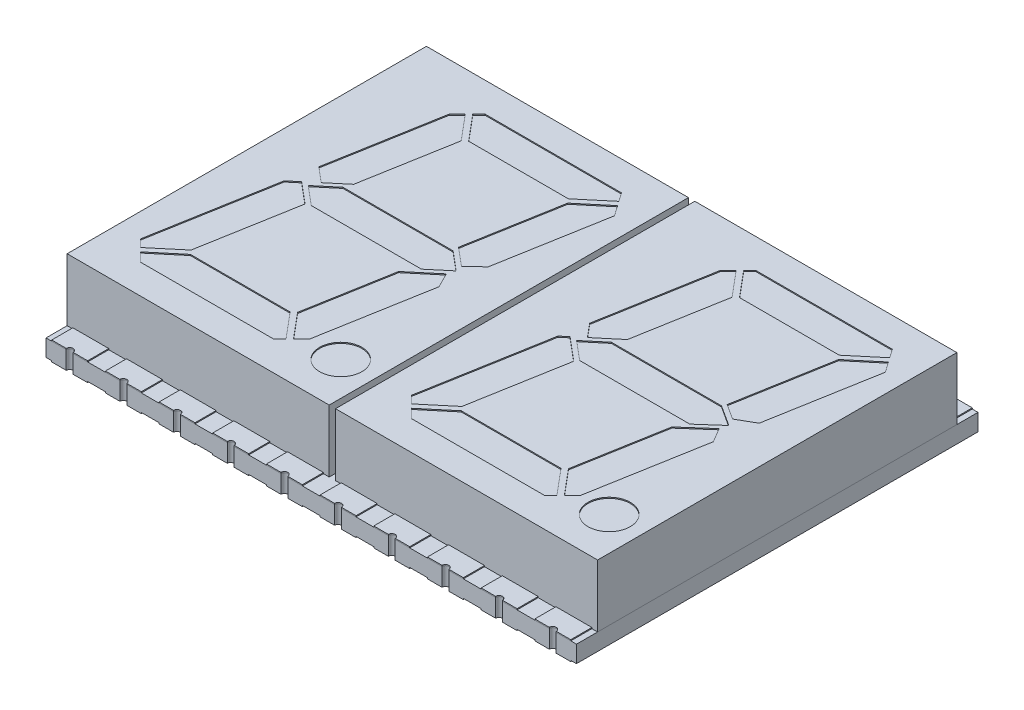
from build123d import *

# Parameters (mm, degrees)
SKETCH1_W          = 25.1
SKETCH1_H          = 17
EXTRUDE1_DEPTH     = 2.95
SKETCH2_R          = 1
CUT_EXTRUDE1_DEPTH = 0.05
SKETCH3_W          = 25.1
SKETCH3_H          = 19
EXTRUDE2_DEPTH     = 0.8
EXTRUDE3_DEPTH     = 0.05
EXTRUDE3_2_DEPTH   = 0.05
EXTRUDE3_3_DEPTH   = 0.05
EXTRUDE3_4_DEPTH   = 0.05
EXTRUDE3_5_DEPTH   = 0.05
EXTRUDE3_6_DEPTH   = 0.05
EXTRUDE3_7_DEPTH   = 0.05
EXTRUDE3_8_DEPTH   = 0.05
EXTRUDE3_9_DEPTH   = 0.05
EXTRUDE3_10_DEPTH  = 0.05
EXTRUDE3_11_DEPTH  = 0.05
EXTRUDE3_12_DEPTH  = 0.05
EXTRUDE3_13_DEPTH  = 0.05
EXTRUDE3_14_DEPTH  = 0.05
EXTRUDE3_15_DEPTH  = 0.05
EXTRUDE3_16_DEPTH  = 0.05
EXTRUDE3_17_DEPTH  = 0.05
EXTRUDE3_18_DEPTH  = 0.05
EXTRUDE3_19_DEPTH  = 0.05
EXTRUDE3_20_DEPTH  = 0.05
SKETCH5_W          = 1.7
SKETCH5_H          = 1.5
EXTRUDE4_DEPTH     = 0.05
SKETCH10_5_R       = 0.1625
CUT_EXTRUDE2_DEPTH = 1.85
CUT_EXTRUDE5_START = -3.8
SKETCH13_W         = 0.3
SKETCH13_H         = 17
CUT_EXTRUDE5_DEPTH = 3.8


with BuildPart() as part:
    # Sketch1 → Extrude1 (new body)
    with BuildSketch(Plane(origin=(0, 0, 0), x_dir=(1, 0, 0), z_dir=(0, 1, 0))):
        Rectangle(SKETCH1_W, SKETCH1_H)
    extrude(amount=-EXTRUDE1_DEPTH)

    # Sketch2 → Cut-Extrude1 (cut)
    with BuildSketch(Plane(origin=(0, 0, 0), x_dir=(-1, 0, 0), z_dir=(0, 1, 0))):
        Polygon((8.852866064, -6.641245818), (9.232640019, -6.261471863), (10.157474308, -1.016475976), (9.44999247, -0.422828228), (8.615549782, -1.12300878), (7.852707368, -5.449303098), align=None)
        Polygon((1.928929028, -7.11), (8.384111882, -7.11), (8.675414111, -6.818697771), (7.661196257, -5.61), (2.941704587, -5.61), (1.642158235, -6.700448864), align=None)
        Polygon((9.95389953, 0), (10.403180171, 0.37699122), (11.422070575, 6.155405845), (11.068538667, 6.508937754), (9.768992316, 5.418488889), (8.960539945, 0.833527661), align=None)
        Polygon((1.154600839, -6.00414474), (1.498216384, -6.494878596), (2.781007684, -5.418488889), (3.55537083, -1.026857262), (2.693597993, -0.303743992), (2.049432878, -0.929300064), align=None)
        Polygon((8.74893957, -0.75), (9.642754764, 0), (8.74893957, 0.75), (3.536569959, 0.75), (2.642754764, 0), (3.536569959, -0.75), align=None)
        Polygon((9.608295413, 5.61), (10.891086714, 6.686389707), (10.467476421, 7.11), (4.165888118, 7.11), (3.874585889, 6.818697771), (4.888803743, 5.61), align=None)
        Polygon((2.753218376, 0.353771434), (3.980378506, 1.383481046), (4.697292632, 5.449303098), (3.697133936, 6.641245818), (3.317359981, 6.261471863), (2.399465611, 1.055834211), align=None)
        Polygon((-1.926170809, 6.686369054), (-2.349801757, 7.110000002), (-8.65139006, 7.110000002), (-8.942693927, 6.818696135), (-7.928477445, 5.61), (-3.208937491, 5.61), align=None)
        Polygon((-1.395207603, 6.155405848), (-1.748760165, 6.50895841), (-3.048277997, 5.418533472), (-3.841622667, 0.919252271), (-2.746100468, -1e-09), (-2.43446315, 0.261494758), align=None)
        Polygon((-8.119985018, 5.449306065), (-9.120142603, 6.641247459), (-9.499918197, 6.261471865), (-10.442385385, 0.91647484), (-10.042176652, 0.239816778), (-8.853130118, 1.291433592), align=None)
        Polygon((-3.95106043, 0.75), (-9.163430041, 0.75), (-10.143402684, -0.116707634), (-9.163430041, -0.75), (-3.95106043, -0.75), (-3.057245236, 0), align=None)
        Polygon((-2.65980387, -1.016475974), (-3.193889851, -0.375739907), (-4.222093533, -1.238505238), (-4.964570806, -5.449303098), (-3.964412113, -6.641245814), (-3.584638159, -6.26147186), align=None)
        Polygon((-9.245703338, -0.934959776), (-9.96734652, -0.468608882), (-10.7678453, -0.929300061), (-11.662677339, -6.004144738), (-11.319061794, -6.494878594), (-10.036270496, -5.418488889), align=None)
        Polygon((-4.141864066, -6.818697768), (-5.156081917, -5.61), (-9.875573594, -5.61), (-11.175119943, -6.700448862), (-10.88834915, -7.109999998), (-4.433166296, -7.109999998), align=None)
        with Locations(Location((1.742754764, 6.36, 0), (0, 0, 90))):  # turned: the seam where the file's is
            Circle(SKETCH2_R)
        with Locations(Location((-10.957245236, 6.36, 0), (0, 0, 90))):  # turned: the seam where the file's is
            Circle(SKETCH2_R)
    extrude(amount=-CUT_EXTRUDE1_DEPTH, mode=Mode.SUBTRACT)

    # Sketch13 → Cut-Extrude5 (cut)
    with BuildSketch(Plane(origin=(0, 0, 0), x_dir=(-1, 0, 0), z_dir=(0, 1, 0)).offset(CUT_EXTRUDE5_START)):
        Rectangle(SKETCH13_W, SKETCH13_H)
    extrude(amount=CUT_EXTRUDE5_DEPTH, mode=Mode.SUBTRACT)


with BuildPart() as body_2:
    # Sketch3 → Extrude2 (new body)
    with BuildSketch(Plane.XZ.offset(2.95)):
        Rectangle(SKETCH3_W, SKETCH3_H)
    extrude(amount=EXTRUDE2_DEPTH)

    # Sketch5 → Extrude4 (add)
    with BuildSketch(Plane.XZ.offset(3.75)):
        with Locations((11.43, -8.75)):
            Rectangle(SKETCH5_W, SKETCH5_H)
        with Locations((8.89, -8.75)):
            Rectangle(SKETCH5_W, SKETCH5_H)
        with Locations((6.35, -8.75)):
            Rectangle(SKETCH5_W, SKETCH5_H)
        with Locations((3.81, -8.75)):
            Rectangle(SKETCH5_W, SKETCH5_H)
        with Locations((1.27, -8.75)):
            Rectangle(SKETCH5_W, SKETCH5_H)
        with Locations((-1.27, -8.75)):
            Rectangle(SKETCH5_W, SKETCH5_H)
        with Locations((-3.81, -8.75)):
            Rectangle(SKETCH5_W, SKETCH5_H)
        with Locations((-6.35, -8.75)):
            Rectangle(SKETCH5_W, SKETCH5_H)
        with Locations((-8.89, -8.75)):
            Rectangle(SKETCH5_W, SKETCH5_H)
        with Locations((-11.43, -8.75)):
            Rectangle(SKETCH5_W, SKETCH5_H)
        with Locations((11.43, 8.75)):
            Rectangle(SKETCH5_W, SKETCH5_H)
        with Locations((8.89, 8.75)):
            Rectangle(SKETCH5_W, SKETCH5_H)
        with Locations((6.35, 8.75)):
            Rectangle(SKETCH5_W, SKETCH5_H)
        with Locations((3.81, 8.75)):
            Rectangle(SKETCH5_W, SKETCH5_H)
        with Locations((1.27, 8.75)):
            Rectangle(SKETCH5_W, SKETCH5_H)
        with Locations((-1.27, 8.75)):
            Rectangle(SKETCH5_W, SKETCH5_H)
        with Locations((-3.81, 8.75)):
            Rectangle(SKETCH5_W, SKETCH5_H)
        with Locations((-6.35, 8.75)):
            Rectangle(SKETCH5_W, SKETCH5_H)
        with Locations((-8.89, 8.75)):
            Rectangle(SKETCH5_W, SKETCH5_H)
        with Locations((-11.43, 8.75)):
            Rectangle(SKETCH5_W, SKETCH5_H)
    extrude(amount=EXTRUDE4_DEPTH)

    # Sketch10_5 → Cut-Extrude2 (cut, through all)
    with BuildSketch(Plane(origin=(0, -2.95, 0), x_dir=(-1, 0, 0), z_dir=(0, 1, 0))):
        with BuildLine():
            ThreePointArc((11.2675, 9.5), (11.43, 9.3375), (11.5925, 9.5))
            Line((11.5925, 9.5), (11.2675, 9.5))
        make_face()
        with BuildLine():
            Line((11.2675, 9.5), (11.5925, 9.5))
            ThreePointArc((11.5925, 9.5), (11.43, 9.6625), (11.2675, 9.5))
        make_face()
        with Locations((-6.35, -9.5)):
            Circle(SKETCH10_5_R)
        with Locations((-11.43, -9.5)):
            Circle(SKETCH10_5_R)
        with Locations((-8.89, -9.5)):
            Circle(SKETCH10_5_R)
        with Locations((-3.81, -9.5)):
            Circle(SKETCH10_5_R)
        with Locations((-1.27, -9.5)):
            Circle(SKETCH10_5_R)
        with Locations((1.27, -9.5)):
            Circle(SKETCH10_5_R)
        with Locations((3.81, -9.5)):
            Circle(SKETCH10_5_R)
        with Locations((6.35, -9.5)):
            Circle(SKETCH10_5_R)
        with Locations((8.89, -9.5)):
            Circle(SKETCH10_5_R)
        with Locations((11.43, -9.5)):
            Circle(SKETCH10_5_R)
        with Locations((-11.43, 9.5)):
            Circle(SKETCH10_5_R)
        with Locations((-8.89, 9.5)):
            Circle(SKETCH10_5_R)
        with Locations((-6.35, 9.5)):
            Circle(SKETCH10_5_R)
        with Locations((-3.81, 9.5)):
            Circle(SKETCH10_5_R)
        with Locations((-1.27, 9.5)):
            Circle(SKETCH10_5_R)
        with Locations((1.27, 9.5)):
            Circle(SKETCH10_5_R)
        with Locations((3.81, 9.5)):
            Circle(SKETCH10_5_R)
        with Locations((6.35, 9.5)):
            Circle(SKETCH10_5_R)
        with Locations((8.89, 9.5)):
            Circle(SKETCH10_5_R)
    extrude(amount=-CUT_EXTRUDE2_DEPTH, mode=Mode.SUBTRACT)


with BuildPart() as body_3:
    # Sketch4 → Extrude3 (new body)
    with BuildSketch(Plane(origin=(0, -2.95, 0), x_dir=(-1, 0, 0), z_dir=(0, 1, 0))):
        with BuildLine():
            Line((10.58, 8.5), (12.28, 8.5))
            Line((12.28, 8.5), (12.28, 9.5))
            Line((12.28, 9.5), (11.5925, 9.5))
            ThreePointArc((11.5925, 9.5), (11.43, 9.3375), (11.2675, 9.5))
            Line((11.2675, 9.5), (10.58, 9.5))
            Line((10.58, 9.5), (10.58, 8.5))
        make_face()
    extrude(amount=EXTRUDE3_DEPTH)


with BuildPart() as body_4:
    # Sketch4 → Extrude3 2 (new body)
    with BuildSketch(Plane(origin=(0, -2.95, 0), x_dir=(-1, 0, 0), z_dir=(0, 1, 0))):
        with BuildLine():
            Line((9.74, 8.5), (9.74, 9.5))
            Line((9.74, 9.5), (9.0525, 9.5))
            ThreePointArc((9.0525, 9.5), (8.89, 9.3375), (8.7275, 9.5))
            Line((8.7275, 9.5), (8.04, 9.5))
            Line((8.04, 9.5), (8.04, 8.5))
            Line((8.04, 8.5), (9.74, 8.5))
        make_face()
    extrude(amount=EXTRUDE3_2_DEPTH)


with BuildPart() as body_5:
    # Sketch4 → Extrude3 3 (new body)
    with BuildSketch(Plane(origin=(0, -2.95, 0), x_dir=(-1, 0, 0), z_dir=(0, 1, 0))):
        with BuildLine():
            Line((7.2, 8.5), (7.2, 9.5))
            Line((7.2, 9.5), (6.5125, 9.5))
            ThreePointArc((6.5125, 9.5), (6.35, 9.3375), (6.1875, 9.5))
            Line((6.1875, 9.5), (5.5, 9.5))
            Line((5.5, 9.5), (5.5, 8.5))
            Line((5.5, 8.5), (7.2, 8.5))
        make_face()
    extrude(amount=EXTRUDE3_3_DEPTH)


with BuildPart() as body_6:
    # Sketch4 → Extrude3 4 (new body)
    with BuildSketch(Plane(origin=(0, -2.95, 0), x_dir=(-1, 0, 0), z_dir=(0, 1, 0))):
        with BuildLine():
            Line((4.66, 8.5), (4.66, 9.5))
            Line((4.66, 9.5), (3.9725, 9.5))
            ThreePointArc((3.9725, 9.5), (3.81, 9.3375), (3.6475, 9.5))
            Line((3.6475, 9.5), (2.96, 9.5))
            Line((2.96, 9.5), (2.96, 8.5))
            Line((2.96, 8.5), (4.66, 8.5))
        make_face()
    extrude(amount=EXTRUDE3_4_DEPTH)


with BuildPart() as body_7:
    # Sketch4 → Extrude3 5 (new body)
    with BuildSketch(Plane(origin=(0, -2.95, 0), x_dir=(-1, 0, 0), z_dir=(0, 1, 0))):
        with BuildLine():
            Line((2.12, 8.5), (2.12, 9.5))
            Line((2.12, 9.5), (1.4325, 9.5))
            ThreePointArc((1.4325, 9.5), (1.27, 9.3375), (1.1075, 9.5))
            Line((1.1075, 9.5), (0.42, 9.5))
            Line((0.42, 9.5), (0.42, 8.5))
            Line((0.42, 8.5), (2.12, 8.5))
        make_face()
    extrude(amount=EXTRUDE3_5_DEPTH)


with BuildPart() as body_8:
    # Sketch4 → Extrude3 6 (new body)
    with BuildSketch(Plane(origin=(0, -2.95, 0), x_dir=(-1, 0, 0), z_dir=(0, 1, 0))):
        with BuildLine():
            Line((-0.42, 8.5), (-0.42, 9.5))
            Line((-0.42, 9.5), (-1.1075, 9.5))
            ThreePointArc((-1.1075, 9.5), (-1.27, 9.3375), (-1.4325, 9.5))
            Line((-1.4325, 9.5), (-2.12, 9.5))
            Line((-2.12, 9.5), (-2.12, 8.5))
            Line((-2.12, 8.5), (-0.42, 8.5))
        make_face()
    extrude(amount=EXTRUDE3_6_DEPTH)


with BuildPart() as body_9:
    # Sketch4 → Extrude3 7 (new body)
    with BuildSketch(Plane(origin=(0, -2.95, 0), x_dir=(-1, 0, 0), z_dir=(0, 1, 0))):
        with BuildLine():
            Line((-2.96, 8.5), (-2.96, 9.5))
            Line((-2.96, 9.5), (-3.6475, 9.5))
            ThreePointArc((-3.6475, 9.5), (-3.81, 9.3375), (-3.9725, 9.5))
            Line((-3.9725, 9.5), (-4.66, 9.5))
            Line((-4.66, 9.5), (-4.66, 8.5))
            Line((-4.66, 8.5), (-2.96, 8.5))
        make_face()
    extrude(amount=EXTRUDE3_7_DEPTH)


with BuildPart() as body_10:
    # Sketch4 → Extrude3 8 (new body)
    with BuildSketch(Plane(origin=(0, -2.95, 0), x_dir=(-1, 0, 0), z_dir=(0, 1, 0))):
        with BuildLine():
            Line((-5.5, 8.5), (-5.5, 9.5))
            Line((-5.5, 9.5), (-6.1875, 9.5))
            ThreePointArc((-6.1875, 9.5), (-6.35, 9.3375), (-6.5125, 9.5))
            Line((-6.5125, 9.5), (-7.2, 9.5))
            Line((-7.2, 9.5), (-7.2, 8.5))
            Line((-7.2, 8.5), (-5.5, 8.5))
        make_face()
    extrude(amount=EXTRUDE3_8_DEPTH)


with BuildPart() as body_11:
    # Sketch4 → Extrude3 9 (new body)
    with BuildSketch(Plane(origin=(0, -2.95, 0), x_dir=(-1, 0, 0), z_dir=(0, 1, 0))):
        with BuildLine():
            Line((-8.04, 8.5), (-8.04, 9.5))
            Line((-8.04, 9.5), (-8.7275, 9.5))
            ThreePointArc((-8.7275, 9.5), (-8.89, 9.3375), (-9.0525, 9.5))
            Line((-9.0525, 9.5), (-9.74, 9.5))
            Line((-9.74, 9.5), (-9.74, 8.5))
            Line((-9.74, 8.5), (-8.04, 8.5))
        make_face()
    extrude(amount=EXTRUDE3_9_DEPTH)


with BuildPart() as body_12:
    # Sketch4 → Extrude3 10 (new body)
    with BuildSketch(Plane(origin=(0, -2.95, 0), x_dir=(-1, 0, 0), z_dir=(0, 1, 0))):
        with BuildLine():
            Line((-10.58, 8.5), (-10.58, 9.5))
            Line((-10.58, 9.5), (-11.2675, 9.5))
            ThreePointArc((-11.2675, 9.5), (-11.43, 9.3375), (-11.5925, 9.5))
            Line((-11.5925, 9.5), (-12.28, 9.5))
            Line((-12.28, 9.5), (-12.28, 8.5))
            Line((-12.28, 8.5), (-10.58, 8.5))
        make_face()
    extrude(amount=EXTRUDE3_10_DEPTH)


with BuildPart() as body_13:
    # Sketch4 → Extrude3 11 (new body)
    with BuildSketch(Plane(origin=(0, -2.95, 0), x_dir=(-1, 0, 0), z_dir=(0, 1, 0))):
        with BuildLine():
            Line((10.58, -8.5), (10.58, -9.5))
            Line((10.58, -9.5), (11.2675, -9.5))
            ThreePointArc((11.2675, -9.5), (11.43, -9.3375), (11.5925, -9.5))
            Line((11.5925, -9.5), (12.28, -9.5))
            Line((12.28, -9.5), (12.28, -8.5))
            Line((12.28, -8.5), (10.58, -8.5))
        make_face()
    extrude(amount=EXTRUDE3_11_DEPTH)


with BuildPart() as body_14:
    # Sketch4 → Extrude3 12 (new body)
    with BuildSketch(Plane(origin=(0, -2.95, 0), x_dir=(-1, 0, 0), z_dir=(0, 1, 0))):
        with BuildLine():
            Line((8.04, -8.5), (8.04, -9.5))
            Line((8.04, -9.5), (8.7275, -9.5))
            ThreePointArc((8.7275, -9.5), (8.89, -9.3375), (9.0525, -9.5))
            Line((9.0525, -9.5), (9.74, -9.5))
            Line((9.74, -9.5), (9.74, -8.5))
            Line((9.74, -8.5), (8.04, -8.5))
        make_face()
    extrude(amount=EXTRUDE3_12_DEPTH)


with BuildPart() as body_15:
    # Sketch4 → Extrude3 13 (new body)
    with BuildSketch(Plane(origin=(0, -2.95, 0), x_dir=(-1, 0, 0), z_dir=(0, 1, 0))):
        with BuildLine():
            Line((5.5, -8.5), (5.5, -9.5))
            Line((5.5, -9.5), (6.1875, -9.5))
            ThreePointArc((6.1875, -9.5), (6.35, -9.3375), (6.5125, -9.5))
            Line((6.5125, -9.5), (7.2, -9.5))
            Line((7.2, -9.5), (7.2, -8.5))
            Line((7.2, -8.5), (5.5, -8.5))
        make_face()
    extrude(amount=EXTRUDE3_13_DEPTH)


with BuildPart() as body_16:
    # Sketch4 → Extrude3 14 (new body)
    with BuildSketch(Plane(origin=(0, -2.95, 0), x_dir=(-1, 0, 0), z_dir=(0, 1, 0))):
        with BuildLine():
            Line((2.96, -8.5), (2.96, -9.5))
            Line((2.96, -9.5), (3.6475, -9.5))
            ThreePointArc((3.6475, -9.5), (3.81, -9.3375), (3.9725, -9.5))
            Line((3.9725, -9.5), (4.66, -9.5))
            Line((4.66, -9.5), (4.66, -8.5))
            Line((4.66, -8.5), (2.96, -8.5))
        make_face()
    extrude(amount=EXTRUDE3_14_DEPTH)


with BuildPart() as body_17:
    # Sketch4 → Extrude3 15 (new body)
    with BuildSketch(Plane(origin=(0, -2.95, 0), x_dir=(-1, 0, 0), z_dir=(0, 1, 0))):
        with BuildLine():
            Line((0.42, -8.5), (0.42, -9.5))
            Line((0.42, -9.5), (1.1075, -9.5))
            ThreePointArc((1.1075, -9.5), (1.27, -9.3375), (1.4325, -9.5))
            Line((1.4325, -9.5), (2.12, -9.5))
            Line((2.12, -9.5), (2.12, -8.5))
            Line((2.12, -8.5), (0.42, -8.5))
        make_face()
    extrude(amount=EXTRUDE3_15_DEPTH)


with BuildPart() as body_18:
    # Sketch4 → Extrude3 16 (new body)
    with BuildSketch(Plane(origin=(0, -2.95, 0), x_dir=(-1, 0, 0), z_dir=(0, 1, 0))):
        with BuildLine():
            Line((-2.12, -8.5), (-2.12, -9.5))
            Line((-2.12, -9.5), (-1.4325, -9.5))
            ThreePointArc((-1.4325, -9.5), (-1.27, -9.3375), (-1.1075, -9.5))
            Line((-1.1075, -9.5), (-0.42, -9.5))
            Line((-0.42, -9.5), (-0.42, -8.5))
            Line((-0.42, -8.5), (-2.12, -8.5))
        make_face()
    extrude(amount=EXTRUDE3_16_DEPTH)


with BuildPart() as body_19:
    # Sketch4 → Extrude3 17 (new body)
    with BuildSketch(Plane(origin=(0, -2.95, 0), x_dir=(-1, 0, 0), z_dir=(0, 1, 0))):
        with BuildLine():
            Line((-4.66, -8.5), (-4.66, -9.5))
            Line((-4.66, -9.5), (-3.9725, -9.5))
            ThreePointArc((-3.9725, -9.5), (-3.81, -9.3375), (-3.6475, -9.5))
            Line((-3.6475, -9.5), (-2.96, -9.5))
            Line((-2.96, -9.5), (-2.96, -8.5))
            Line((-2.96, -8.5), (-4.66, -8.5))
        make_face()
    extrude(amount=EXTRUDE3_17_DEPTH)


with BuildPart() as body_20:
    # Sketch4 → Extrude3 18 (new body)
    with BuildSketch(Plane(origin=(0, -2.95, 0), x_dir=(-1, 0, 0), z_dir=(0, 1, 0))):
        with BuildLine():
            Line((-7.2, -8.5), (-7.2, -9.5))
            Line((-7.2, -9.5), (-6.5125, -9.5))
            ThreePointArc((-6.5125, -9.5), (-6.35, -9.3375), (-6.1875, -9.5))
            Line((-6.1875, -9.5), (-5.5, -9.5))
            Line((-5.5, -9.5), (-5.5, -8.5))
            Line((-5.5, -8.5), (-7.2, -8.5))
        make_face()
    extrude(amount=EXTRUDE3_18_DEPTH)


with BuildPart() as body_21:
    # Sketch4 → Extrude3 19 (new body)
    with BuildSketch(Plane(origin=(0, -2.95, 0), x_dir=(-1, 0, 0), z_dir=(0, 1, 0))):
        with BuildLine():
            Line((-9.74, -8.5), (-9.74, -9.5))
            Line((-9.74, -9.5), (-9.0525, -9.5))
            ThreePointArc((-9.0525, -9.5), (-8.89, -9.3375), (-8.7275, -9.5))
            Line((-8.7275, -9.5), (-8.04, -9.5))
            Line((-8.04, -9.5), (-8.04, -8.5))
            Line((-8.04, -8.5), (-9.74, -8.5))
        make_face()
    extrude(amount=EXTRUDE3_19_DEPTH)


with BuildPart() as body_22:
    # Sketch4 → Extrude3 20 (new body)
    with BuildSketch(Plane(origin=(0, -2.95, 0), x_dir=(-1, 0, 0), z_dir=(0, 1, 0))):
        with BuildLine():
            Line((-10.58, -8.5), (-12.28, -8.5))
            Line((-12.28, -8.5), (-12.28, -9.5))
            Line((-12.28, -9.5), (-11.5925, -9.5))
            ThreePointArc((-11.5925, -9.5), (-11.43, -9.3375), (-11.2675, -9.5))
            Line((-11.2675, -9.5), (-10.58, -9.5))
            Line((-10.58, -9.5), (-10.58, -8.5))
        make_face()
    extrude(amount=EXTRUDE3_20_DEPTH)


solid = Compound([part.part, body_2.part, body_3.part, body_4.part, body_5.part, body_6.part, body_7.part, body_8.part, body_9.part, body_10.part, body_11.part, body_12.part, body_13.part, body_14.part, body_15.part, body_16.part, body_17.part, body_18.part, body_19.part, body_20.part, body_21.part, body_22.part])
